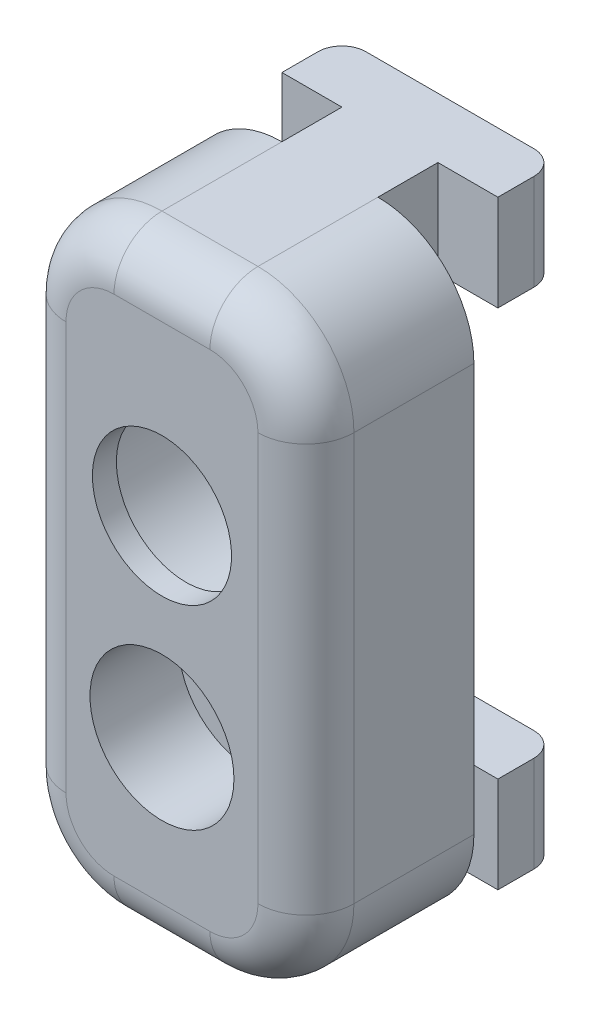
from build123d import *

# Parameters (mm, degrees)
BOSS_EXTRU_3_DEPTH      = 4
ESQUISSE3_W             = 12
ESQUISSE3_H             = 7
BOSS_EXTRU_4_DEPTH      = 8.5
ENL_V_MAT_EXTRU_1_REACH = 9
ESQUISSE4_R             = 1.65
ESQUISSE4_R_2           = 2.9
ESQUISSE5_R             = 4.1
ENL_V_MAT_EXTRU_2_DEPTH = 6
CONG_1_R                = 4
CONG_2_R                = 2
ESQUISSE6_R             = 3
ENL_V_MAT_EXTRU_3_DEPTH = 3.7
ENL_V_MAT_EXTRU_4_DEPTH = 2


with BuildPart() as part:
    # Esquisse2 → Boss.-Extru.3 (new body)
    with BuildSketch(Plane(origin=(0, 0, 0), x_dir=(1, 0, 0), z_dir=(0, 1, 0))):
        with BuildLine():
            Line((11.568725398, 38.128215269), (18.568725398, 38.128215269))
            ThreePointArc((18.568725398, 38.128215269), (19.275832179, 37.83532205), (19.568725398, 37.128215269))
            Line((19.568725398, 37.128215269), (19.568725398, 35.628215269))
            Line((19.568725398, 35.628215269), (17.068725398, 35.628215269))
            Line((17.068725398, 35.628215269), (17.068725398, 33.128215269))
            Line((17.068725398, 33.128215269), (21.068725398, 33.128215269))
            Line((21.068725398, 33.128215269), (21.068725398, 26.128215269))
            Line((21.068725398, 26.128215269), (9.068725398, 26.128215269))
            Line((9.068725398, 26.128215269), (9.068725398, 33.128215269))
            Line((9.068725398, 33.128215269), (13.068725398, 33.128215269))
            Line((13.068725398, 33.128215269), (13.068725398, 35.628215269))
            Line((13.068725398, 35.628215269), (10.568725398, 35.628215269))
            Line((10.568725398, 35.628215269), (10.568725398, 37.128215269))
            ThreePointArc((10.568725398, 37.128215269), (10.861618616, 37.83532205), (11.568725398, 38.128215269))
        make_face()
    extrude(amount=BOSS_EXTRU_3_DEPTH)

    # Esquisse3 → Boss.-Extru.4 (add)
    with BuildSketch(Plane(origin=(0, 4, 0), x_dir=(1, 0, 0), z_dir=(0, 1, 0))):
        with Locations((15.068725398, 29.628215269)):
            Rectangle(ESQUISSE3_W, ESQUISSE3_H)
    extrude(amount=BOSS_EXTRU_4_DEPTH)

    # Symétrie1: part across plane


with BuildPart() as part_1:
    add(part.part)
    add(part.part.mirror(Plane.ZX.offset(12.5)))

    # Esquisse4 → Enlèv. mat.-Extru.1 (cut, up to next)
    with BuildSketch(Plane(origin=(0, 0, -33.128215269), x_dir=(-1, 0, 0), z_dir=(0, 0, -1)), mode=Mode.PRIVATE) as enl_v_mat_extru_1_sk1:
        with Locations((-15.068725398, 8)):
            Circle(ESQUISSE4_R)
    enl_v_mat_extru_1_tool1 = extrude(enl_v_mat_extru_1_sk1.sketch, amount=-ENL_V_MAT_EXTRU_1_REACH, mode=Mode.PRIVATE) & part_1.part
    add(enl_v_mat_extru_1_tool1.solids().sort_by_distance((15.068725, 8, -33.128215))[0], mode=Mode.SUBTRACT)
    # Esquisse4 → Enlèv. mat.-Extru.1 (cut, up to next)
    with BuildSketch(Plane(origin=(0, 0, -33.128215269), x_dir=(-1, 0, 0), z_dir=(0, 0, -1)), mode=Mode.PRIVATE) as enl_v_mat_extru_1_sk2:
        with Locations((-15.068725398, 16)):
            Circle(ESQUISSE4_R_2)
    enl_v_mat_extru_1_tool2 = extrude(enl_v_mat_extru_1_sk2.sketch, amount=-ENL_V_MAT_EXTRU_1_REACH, mode=Mode.PRIVATE) & part_1.part
    add(enl_v_mat_extru_1_tool2.solids().sort_by_distance((15.068725, 16, -33.128215))[0], mode=Mode.SUBTRACT)

    # Esquisse5 → Enlèv. mat.-Extru.2 (cut)
    with BuildSketch(Plane(origin=(0, 0, -33.128215269), x_dir=(-1, 0, 0), z_dir=(0, 0, -1))):
        with Locations((-15.068725398, 16)):
            Circle(ESQUISSE5_R)
    extrude(amount=-ENL_V_MAT_EXTRU_2_DEPTH, mode=Mode.SUBTRACT)

    # Congé1
    cong_1_edges = [part_1.edges().sort_by_distance(p)[0] for p in [
        (9.068725398, 0, -29.628215269),
        (9.068725398, 25, -29.628215269),
        (21.068725398, 0, -29.628215269),
        (21.068725398, 25, -29.628215269),
    ]]
    fillet(cong_1_edges, radius=CONG_1_R)

    # Congé2
    cong_2_edges = [part_1.edges().sort_by_distance(p)[0] for p in [
        (9.068725398, 12.5, -26.128215269),
        (15.068725398, 0, -26.128215269),
        (21.068725398, 12.5, -26.128215269),
        (15.068725398, 25, -26.128215269),
        (19.897152522, 23.828427125, -26.128215269),
        (19.897152522, 1.171572875, -26.128215269),
        (10.240298273, 23.828427125, -26.128215269),
        (10.240298273, 1.171572875, -26.128215269),
    ]]
    fillet(cong_2_edges, radius=CONG_2_R)

    # Esquisse6 → Enlèv. mat.-Extru.3 (cut)
    with BuildSketch(Plane.XY.offset(-26.128215269)):
        with Locations((15.068725398, 8)):
            Circle(ESQUISSE6_R)
    extrude(amount=-ENL_V_MAT_EXTRU_3_DEPTH, mode=Mode.SUBTRACT)

    # Esquisse7 → Enlèv. mat.-Extru.4 (cut)
    with BuildSketch(Plane(origin=(0, 0, -33.128215269), x_dir=(-1, 0, 0), z_dir=(0, 0, -1))):
        Polygon((-16.714173665, 10.85), (-13.42327713, 10.85), (-11.777828863, 8), (-13.42327713, 5.15), (-16.714173665, 5.15), (-18.359621932, 8), align=None)
    extrude(amount=-ENL_V_MAT_EXTRU_4_DEPTH, mode=Mode.SUBTRACT)


solid = part_1.part
